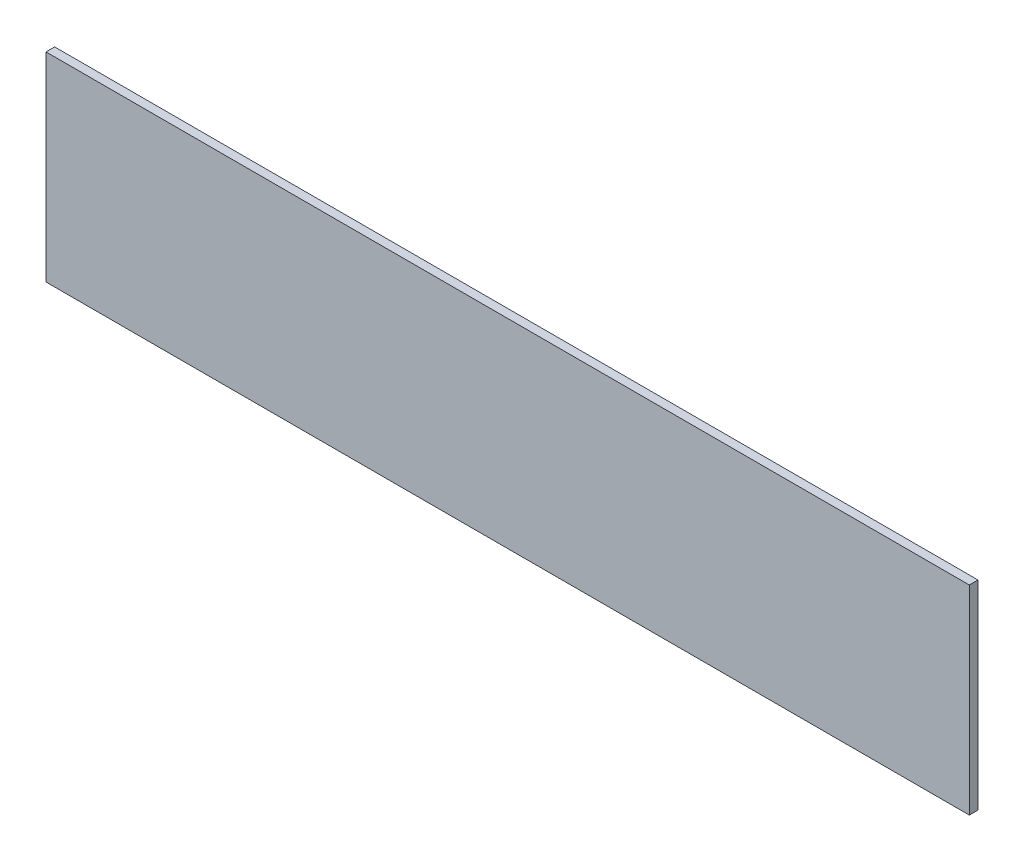
from build123d import *

# Parameters (mm, degrees)
SKETCH1_W           = 338.325
SKETCH1_H           = 73.025
BOSS_EXTRUDE1_DEPTH = 3.175


with BuildPart() as part:
    # Sketch1 → Boss-Extrude1 (new body)
    with BuildSketch(Plane.XY):
        with Locations((170.75, 39.6875)):
            Rectangle(SKETCH1_W, SKETCH1_H)
    extrude(amount=-BOSS_EXTRUDE1_DEPTH)


solid = part.part
